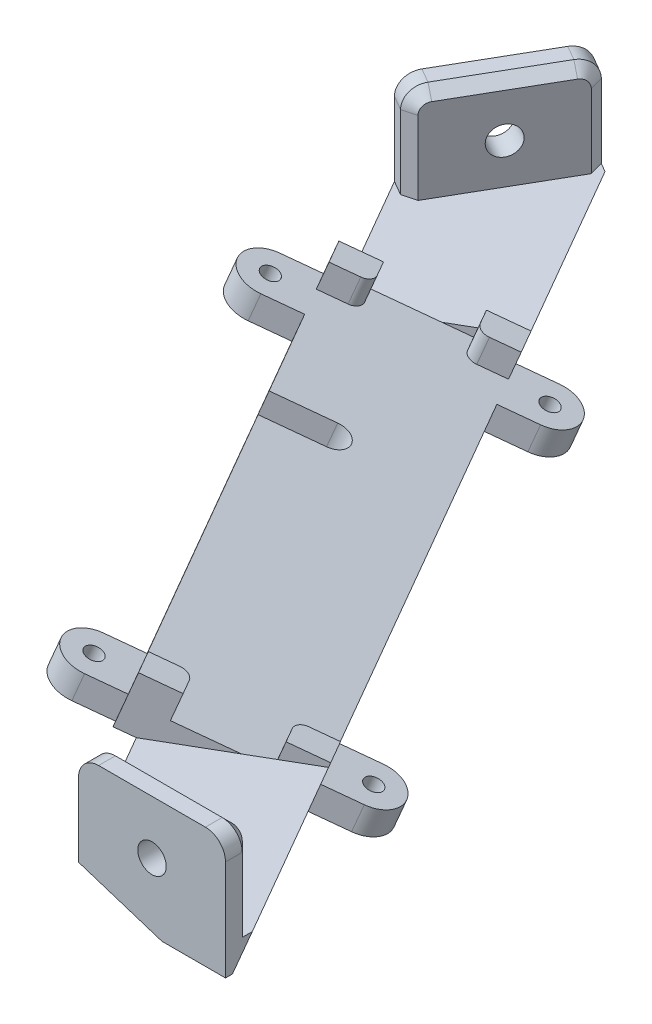
from build123d import *

# Parameters (mm, degrees)
BOSS_EXTRUDE1_DEPTH      = 4
BOSS_EXTRUDE2_DEPTH      = 14
CUT_EXTRUDE3_DEPTH       = 15
CUT_EXTRUDE4_DEPTH       = 5
SKETCH7_R                = 2.125
CUT_EXTRUDE5_DEPTH       = 4
SKETCH8_R                = 2.125
CUT_EXTRUDE6_DEPTH       = 4
FILLET1_R                = 3
CHAMFER1_SIZE            = 1.5
BOSS_EXTRUDE3_DEPTH      = 40.85
BOSS_EXTRUDE3_DEPTH_BACK = 40.85
CUT_EXTRUDE7_DEPTH       = 76.384173958
CUT_EXTRUDE7_DEPTH_BACK  = 81.869001515
CUT_EXTRUDE8_DEPTH       = 3.3077
BOSS_EXTRUDE4_DEPTH      = 4
BOSS_EXTRUDE5_DEPTH      = 81.7
CUT_EXTRUDE9_DEPTH       = 30.834988393
SKETCH16_R               = 1.25
BOSS_EXTRUDE6_DEPTH      = 4
CUT_EXTRUDE10_DEPTH      = 35.534173958
CUT_EXTRUDE10_DEPTH_BACK = 122.719001515


with BuildPart() as part:
    # Sketch1 → Boss-Extrude1 (new body)
    with BuildSketch(Plane(origin=(0, 0, 0), x_dir=(1, 0, 0), z_dir=(0, 1, 0))):
        Polygon((81.735026919, 121.569219382), (146.149545762, 10), (170.398257068, 10), (93.859382572, 142.569219382), align=None)
    extrude(amount=BOSS_EXTRUDE1_DEPTH)

    # Sketch2 → Boss-Extrude2 (add)
    with BuildSketch(Plane(origin=(0, 4, 0), x_dir=(1, 0, 0), z_dir=(0, 1, 0))):
        Polygon((93.859382572, 142.569219382), (81.735026919, 121.569219382), (84.044427996, 117.569219382), (96.168783649, 138.569219382), align=None)
        Polygon((146.149545762, 10), (170.398257068, 10), (168.088855991, 14), (143.840144685, 14), align=None)
    extrude(amount=BOSS_EXTRUDE2_DEPTH)

    # Sketch5 → Cut-Extrude3 (cut, through all)
    with BuildSketch(Plane(origin=(0, 4, 0), x_dir=(1, 0, 0), z_dir=(0, 1, 0))):
        Polygon((96.168783649, 138.569219382), (92.704682034, 140.569219382), (93.859382572, 142.569219382), align=None)
        Polygon((81.735026919, 121.569219382), (85.199128534, 119.569219382), (84.044427996, 117.569219382), align=None)
        Polygon((146.149545762, 10), (146.149545762, 14), (143.840144685, 14), align=None)
        Polygon((168.088855991, 14), (168.088855991, 10), (170.398257068, 10), align=None)
    extrude(amount=CUT_EXTRUDE3_DEPTH, mode=Mode.SUBTRACT)

    # Sketch6 → Cut-Extrude4 (cut, through all)
    with BuildSketch(Plane(origin=(0, 4, 0), x_dir=(1, 0, 0), z_dir=(0, 1, 0))):
        Polygon((93.859382572, 142.569219382), (96.168783649, 138.569219382), (92.704682034, 140.569219382), align=None)
        Polygon((168.088855991, 14), (168.088855991, 10), (170.398257068, 10), align=None)
    extrude(amount=-CUT_EXTRUDE4_DEPTH, mode=Mode.SUBTRACT)

    # Sketch7 → Cut-Extrude5 (cut)
    with BuildSketch(Plane.XY.offset(-10)):
        with Locations((157.119200877, 10)):
            Circle(SKETCH7_R)
    extrude(amount=-CUT_EXTRUDE5_DEPTH, mode=Mode.SUBTRACT)

    # Sketch8 → Cut-Extrude6 (cut)
    with BuildSketch(Plane(origin=(8.660254038, 0, 5), x_dir=(-0.5, 0, 0.866025404), z_dir=(-0.866025404, 0, -0.5))):
        with Locations((-157.119200877, 10)):
            Circle(SKETCH8_R)
    extrude(amount=-CUT_EXTRUDE6_DEPTH, mode=Mode.SUBTRACT)

    # Fillet1
    fillet1_edges = [part.edges().sort_by_distance(p)[0] for p in [
        (94.436732841, 18, -139.569219382),
        (83.467077727, 18, -120.569219382),
        (146.149545762, 18, -12),
        (168.088855991, 18, -12),
    ]]
    fillet(fillet1_edges, radius=FILLET1_R)

    # Chamfer1
    chamfer1_edges = [part.edges().sort_by_distance(p)[0] for p in [
        (96.168783649, 9.5, -138.569219382),
        (85.199128534, 9.5, -119.569219382),
        (90.683956091, 18, -129.069219382),
        (85.638468362, 17.121320344, -120.330178286),
        (95.72944382, 17.121320344, -137.808260477),
        (146.149545762, 9.5, -14),
        (157.119200877, 18, -14),
        (168.088855991, 9.5, -14),
        (167.210176335, 17.121320344, -14),
        (147.028225419, 17.121320344, -14),
    ]]
    chamfer(chamfer1_edges, length=CHAMFER1_SIZE)

    # Sketch10 → Boss-Extrude3 (add, two sides)
    with BuildSketch(Plane(origin=(0, 0, 0), x_dir=(0.866025404, 0, -0.5), z_dir=(0.5, 0, 0.866025404))) as boss_extrude3_sk:
        Polygon((152.569219382, 4), (131.569219382, 4), (129.026250632, 4.943910052), (131.569219382, 11.794870108), align=None)
    extrude(amount=BOSS_EXTRUDE3_DEPTH)
    extrude(boss_extrude3_sk.sketch, amount=-BOSS_EXTRUDE3_DEPTH_BACK)

    # Sketch11 → Cut-Extrude7 (cut, two sides)
    with BuildSketch(Plane(origin=(0, 0, 0), x_dir=(0.866025404, 0, -0.5), z_dir=(0.5, 0, 0.866025404))) as cut_extrude7_sk:
        Polygon((152.569219382, 4), (151.084482218, 0), (152.569219382, 0), align=None)
    extrude(amount=CUT_EXTRUDE7_DEPTH, mode=Mode.SUBTRACT)
    extrude(cut_extrude7_sk.sketch, amount=-CUT_EXTRUDE7_DEPTH_BACK, mode=Mode.SUBTRACT)

    # Sketch12 → Cut-Extrude8 (cut)
    with BuildSketch(Plane(origin=(17.130089599, 53.289226321, -9.890061841), x_dir=(0.953509144, -0.29630427, 0.054991745), z_dir=(0.301364086, 0.9375, -0.173992636))):
        Polygon((80.111656223, 97.310988855), (99.184922165, 109.057074429), (142.026671782, 39.490742847), (122.95340584, 27.744657273), align=None)
    extrude(amount=-CUT_EXTRUDE8_DEPTH, mode=Mode.SUBTRACT)

    # Sketch14 → Boss-Extrude4 (add)
    with BuildSketch(Plane(origin=(16.13326761, 50.188257571, -9.314546398), x_dir=(0.953509144, -0.29630427, 0.054991745), z_dir=(0.301364086, 0.9375, -0.173992636))):
        with BuildLine():
            Line((80.111656223, 97.310988855), (84.539378674, 100.037758721))
            Line((84.539378674, 100.037758721), (85.850325725, 97.909046004))
            ThreePointArc((85.850325725, 97.909046004), (86.032422143, 96.775529185), (85.359666325, 95.845250143))
            Line((85.359666325, 95.845250143), (82.209171505, 93.905048508))
            Line((82.209171505, 93.905048508), (80.111656223, 97.310988855))
        make_face()
        with BuildLine():
            Line((99.184922165, 109.057074429), (94.757199714, 106.330304564))
            Line((94.757199714, 106.330304564), (96.068146765, 104.201591847))
            ThreePointArc((96.068146765, 104.201591847), (96.998425806, 103.52883603), (98.131942626, 103.710932448))
            Line((98.131942626, 103.710932448), (101.282437446, 105.651134083))
            Line((101.282437446, 105.651134083), (99.184922165, 109.057074429))
        make_face()
        with BuildLine():
            Line((122.95340584, 27.744657273), (120.855890559, 31.15059762))
            Line((120.855890559, 31.15059762), (124.00638538, 33.090799255))
            ThreePointArc((124.00638538, 33.090799255), (125.139902199, 33.272895673), (126.07018124, 32.600139855))
            Line((126.07018124, 32.600139855), (127.381128291, 30.471427139))
            Line((127.381128291, 30.471427139), (122.95340584, 27.744657273))
        make_face()
        with BuildLine():
            Line((142.026671782, 39.490742847), (137.598949331, 36.763972982))
            Line((137.598949331, 36.763972982), (136.28800228, 38.892685699))
            ThreePointArc((136.28800228, 38.892685699), (136.105905862, 40.026202518), (136.77866168, 40.956481559))
            Line((136.77866168, 40.956481559), (139.929156501, 42.896683194))
            Line((139.929156501, 42.896683194), (142.026671782, 39.490742847))
        make_face()
    extrude(amount=BOSS_EXTRUDE4_DEPTH)

    # Sketch15 → Boss-Extrude5 (add)
    with BuildSketch(Plane(origin=(20.425, 0, 35.377137745), x_dir=(0.866025404, 0, -0.5), z_dir=(0.5, 0, 0.866025404))):
        Polygon((129.026250632, 4.943910052), (150.026250632, -2.850960056), (151.084482218, 0), align=None)
    extrude(amount=-BOSS_EXTRUDE5_DEPTH)

    # Sketch13 → Cut-Extrude9 (cut, through all)
    with BuildSketch(Plane(origin=(16.13326761, 50.188257571, -9.314546398), x_dir=(0.953509144, -0.29630427, 0.054991745), z_dir=(0.301364086, 0.9375, -0.173992636))):
        with BuildLine():
            Line((94.663168486, 73.6822777), (101.47504918, 77.877308262))
            ThreePointArc((101.47504918, 77.877308262), (102.211038279, 80.973002053), (99.115344488, 81.708991152))
            Line((99.115344488, 81.708991152), (92.303463795, 77.51396059))
            Line((92.303463795, 77.51396059), (94.663168486, 73.6822777))
        make_face()
    extrude(amount=-CUT_EXTRUDE9_DEPTH, mode=Mode.SUBTRACT)

    # Sketch16 → Boss-Extrude6 (add)
    with BuildSketch(Plane(origin=(16.13326761, 50.188257571, -9.314546398), x_dir=(0.953509144, -0.29630427, 0.054991745), z_dir=(0.301364086, 0.9375, -0.173992636))):
        with BuildLine():
            Line((99.735519926, 108.163015088), (104.078093869, 110.837347072))
            ThreePointArc((104.078093869, 110.837347072), (109.37516991, 109.577987946), (108.115810785, 104.280911904))
            Line((108.115810785, 104.280911904), (103.773236843, 101.606579921))
            Line((103.773236843, 101.606579921), (99.735519926, 108.163015088))
        make_face()
        with Locations((106.096952327, 107.559129488)):
            Circle(SKETCH16_R, mode=Mode.SUBTRACT)
        with BuildLine():
            Line((76.319680043, 93.742597531), (80.662253985, 96.416929514))
            Line((80.662253985, 96.416929514), (84.699970901, 89.860494347))
            Line((84.699970901, 89.860494347), (80.357396959, 87.186162363))
            ThreePointArc((80.357396959, 87.186162363), (75.060320917, 88.445521489), (76.319680043, 93.742597531))
        make_face()
        with Locations((78.338538501, 90.464379947)):
            Circle(SKETCH16_R, mode=Mode.SUBTRACT)
        with BuildLine():
            Line((141.47607402, 40.384802188), (145.818647962, 43.059134172))
            ThreePointArc((145.818647962, 43.059134172), (147.078007088, 48.356210213), (141.780931046, 49.615569339))
            Line((141.780931046, 49.615569339), (137.438357104, 46.941237356))
            Line((137.438357104, 46.941237356), (141.47607402, 40.384802188))
        make_face()
        with Locations((143.799789504, 46.337351755)):
            Circle(SKETCH16_R, mode=Mode.SUBTRACT)
        with BuildLine():
            Line((118.365091163, 35.195151782), (122.402808079, 28.638716614))
            Line((122.402808079, 28.638716614), (118.060234137, 25.964384631))
            ThreePointArc((118.060234137, 25.964384631), (112.763158095, 27.223743756), (114.02251722, 32.520819798))
            Line((114.02251722, 32.520819798), (118.365091163, 35.195151782))
        make_face()
        with Locations((116.041375678, 29.242602214)):
            Circle(SKETCH16_R, mode=Mode.SUBTRACT)
    extrude(amount=-BOSS_EXTRUDE6_DEPTH)

    # Sketch18 → Cut-Extrude10 (cut, two sides)
    with BuildSketch(Plane(origin=(20.425, 0, 35.377137745), x_dir=(0.866025404, 0, -0.5), z_dir=(0.5, 0, 0.866025404))) as cut_extrude10_sk:
        Polygon((131.569219382, 4), (142.345537503, 0), (131.569219382, 0), align=None)
    extrude(amount=CUT_EXTRUDE10_DEPTH, mode=Mode.SUBTRACT)
    extrude(cut_extrude10_sk.sketch, amount=-CUT_EXTRUDE10_DEPTH_BACK, mode=Mode.SUBTRACT)


solid = part.part
